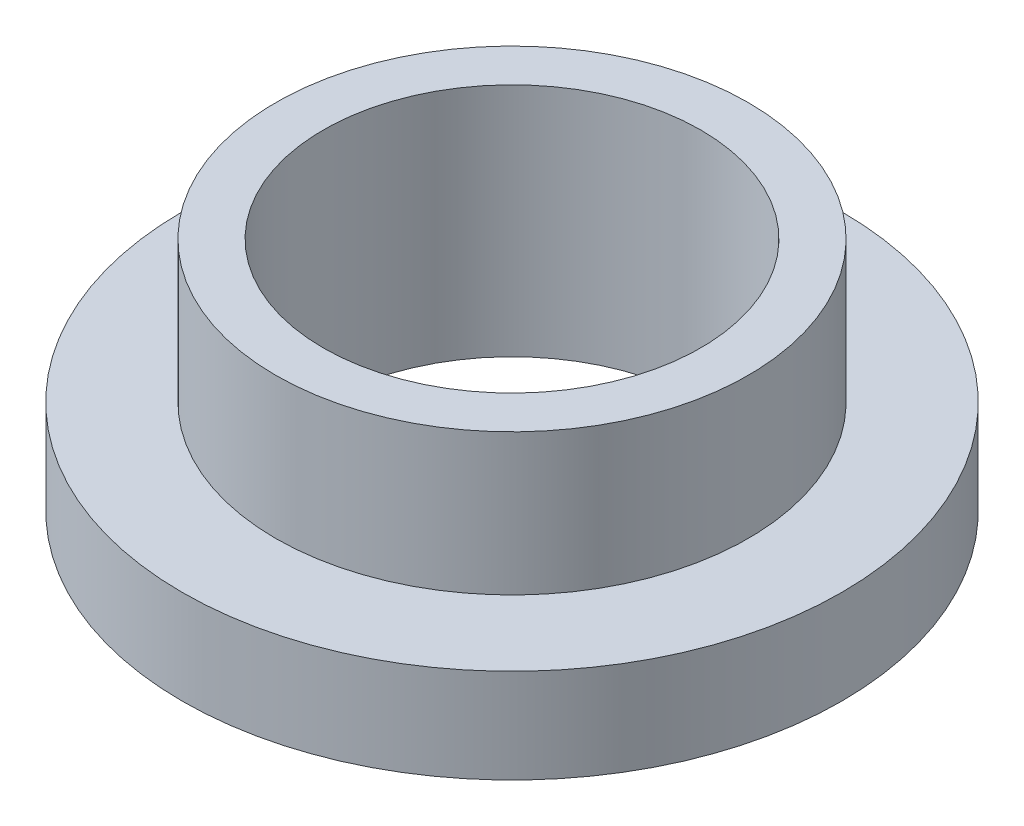
from build123d import *

# Parameters (mm, degrees)
SKETCH2_R           = 7.9629
SKETCH2_R_2         = 6.3627
BOSS_EXTRUDE1_DEPTH = 7.9375
SKETCH3_R           = 11.1125
SKETCH3_R_2         = 7.9629
BOSS_EXTRUDE2_DEPTH = 3.175


with BuildPart() as part:
    # Sketch2 → Boss-Extrude1 (new body)
    with BuildSketch(Plane(origin=(0, 0, 0), x_dir=(1, 0, 0), z_dir=(0, 1, 0))):
        Circle(SKETCH2_R)
        Circle(SKETCH2_R_2, mode=Mode.SUBTRACT)
    extrude(amount=BOSS_EXTRUDE1_DEPTH)

    # Sketch3 → Boss-Extrude2 (add)
    with BuildSketch(Plane(origin=(0, 0, 0), x_dir=(1, 0, 0), z_dir=(0, 1, 0))):
        Circle(SKETCH3_R)
        Circle(SKETCH3_R_2, mode=Mode.SUBTRACT)
    extrude(amount=BOSS_EXTRUDE2_DEPTH)


solid = part.part
